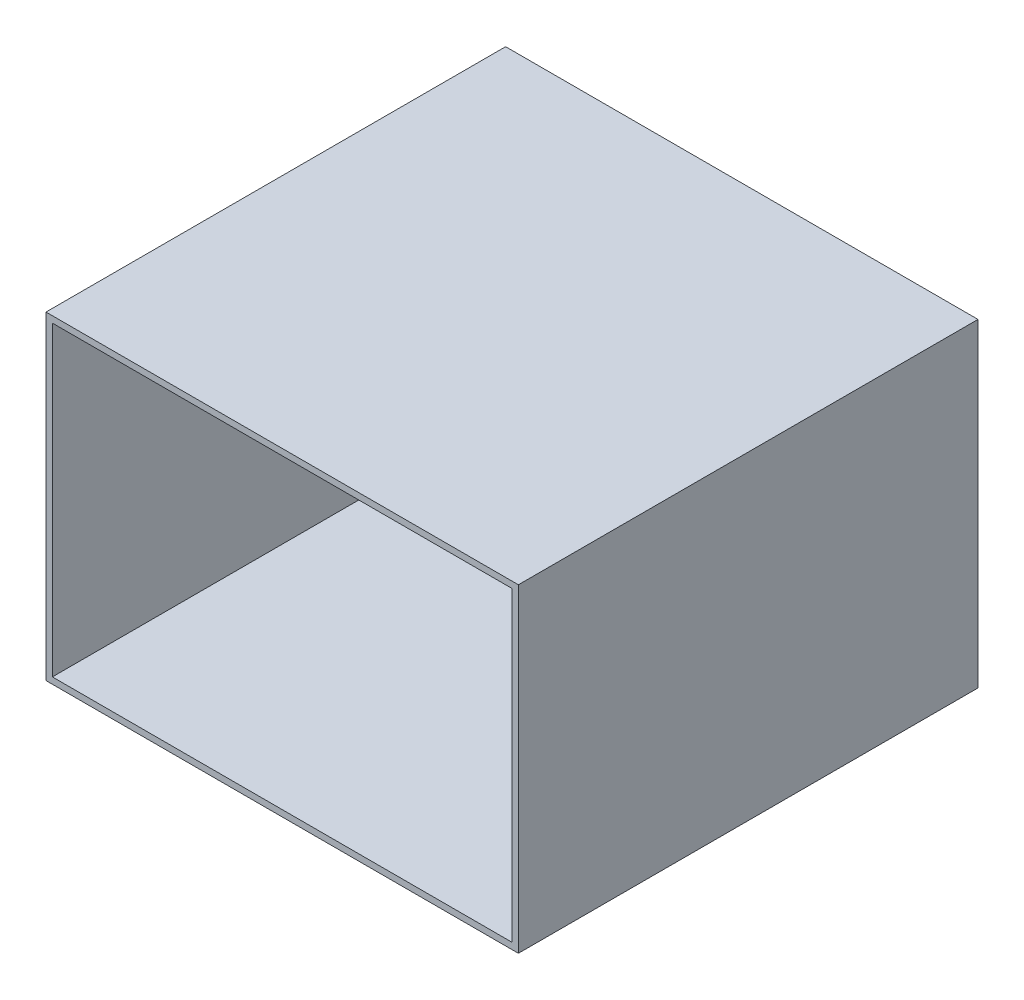
from build123d import *

# Parameters (mm, degrees)
SKETCH1_W           = 457.2
SKETCH1_H           = 304.8
SKETCH1_R           = 25.4
CHAMBER_BASE_DEPTH  = 6.35
SKETCH2_W           = 457.2
SKETCH2_H           = 304.8
BACK_WALL_DEPTH     = 6.35
SKETCH3_W           = 463.55
SKETCH3_H           = 457.2
SIDE_WALL_2_DEPTH   = 6.35
SKETCH5_W           = 463.55
SKETCH5_H           = 457.2
SIDE_WALL_3_DEPTH   = 6.35
SKETCH6_W           = 457.2
SKETCH6_H           = 317.5
BOSS_EXTRUDE1_DEPTH = 6.35


with BuildPart() as part:
    # Sketch1 → Chamber Base (new body)
    with BuildSketch(Plane.XY):
        with Locations((228.6, 152.4)):
            Rectangle(SKETCH1_W, SKETCH1_H)
        with Locations((228.6, 152.4)):
            Circle(SKETCH1_R, mode=Mode.SUBTRACT)
    extrude(amount=CHAMBER_BASE_DEPTH)

    # Sketch2 → Back wall (add)
    with BuildSketch(Plane(origin=(457.2, 0, 0), x_dir=(0, 0, -1), z_dir=(1, 0, 0))):
        with Locations((-228.6, 152.4)):
            Rectangle(SKETCH2_W, SKETCH2_H)
    extrude(amount=BACK_WALL_DEPTH)

    # Sketch3 → Side wall 2 (add)
    with BuildSketch(Plane(origin=(0, 304.8, 0), x_dir=(1, 0, 0), z_dir=(0, 1, 0))):
        with Locations((231.775, -228.6)):
            Rectangle(SKETCH3_W, SKETCH3_H)
    extrude(amount=SIDE_WALL_2_DEPTH)

    # Sketch5 → Side wall 3 (add)
    with BuildSketch(Plane.XZ):
        with Locations((231.775, 228.6)):
            Rectangle(SKETCH5_W, SKETCH5_H)
    extrude(amount=SIDE_WALL_3_DEPTH)

    # Sketch6 → Boss-Extrude1 (add)
    with BuildSketch(Plane.ZY):
        with Locations((228.6, 152.4)):
            Rectangle(SKETCH6_W, SKETCH6_H)
    extrude(amount=BOSS_EXTRUDE1_DEPTH)


solid = part.part
